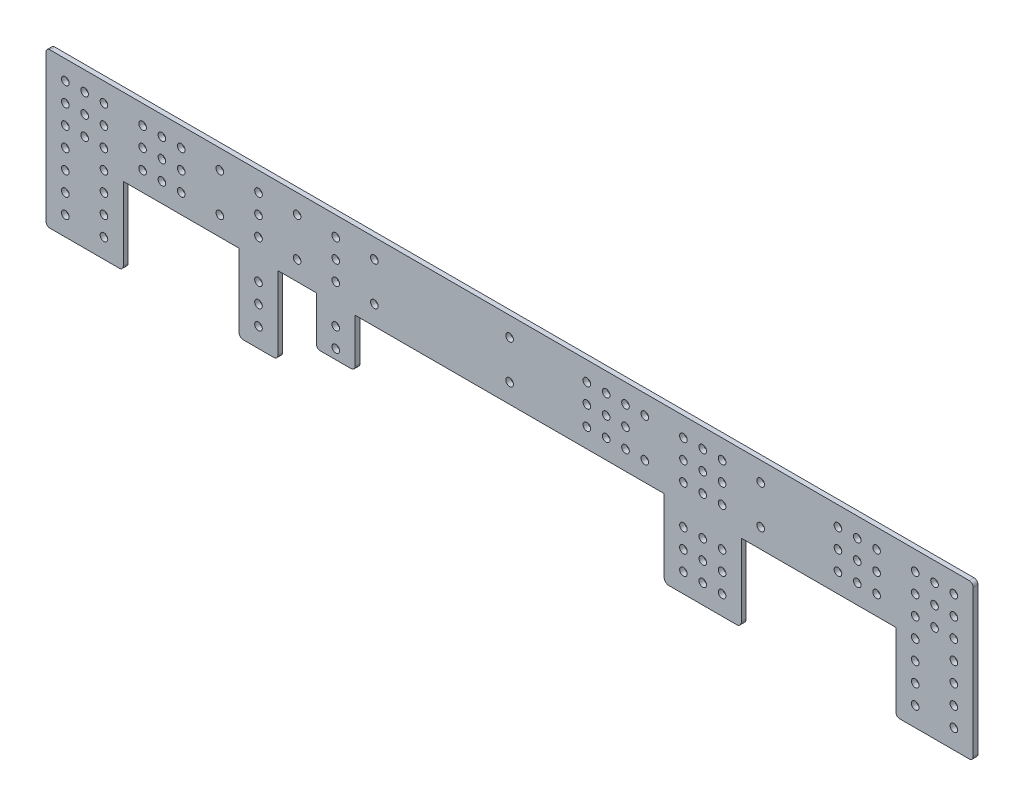
from build123d import *

# Parameters (mm, degrees)
BOSS_EXTRUDE1_DEPTH = 3.175
BOSS_EXTRUDE2_DEPTH = 3.175
BOSS_EXTRUDE3_DEPTH = 3.175
SKETCH7_R           = 2.505
SKETCH7_R_2         = 2.5
CUT_EXTRUDE3_DEPTH  = 4.175
SKETCH3_R           = 2.505
SKETCH3_R_2         = 2.5
CUT_EXTRUDE4_DEPTH  = 4.175
SKETCH8_R           = 2.5
CUT_EXTRUDE5_DEPTH  = 4.175
SKETCH9_R           = 2.5
CUT_EXTRUDE6_DEPTH  = 4.175


with BuildPart() as part:
    # Sketch2 → Boss-Extrude1 (new body)
    with BuildSketch(Plane.XY):
        with BuildLine():
            Line((126.386816889, -46.477764478), (-478.133183111, -46.477764478))
            ThreePointArc((-478.133183111, -46.477764478), (-479.929234335, -47.221713254), (-480.673183111, -49.017764478))
            Line((-480.673183111, -49.017764478), (-480.673183111, -97.277764478))
            Line((-480.673183111, -97.277764478), (-429.873183111, -97.277764478))
            Line((-429.873183111, -97.277764478), (78.126816889, -97.277764478))
            Line((78.126816889, -97.277764478), (128.926816889, -97.277764478))
            Line((128.926816889, -97.277764478), (128.926816889, -49.017764478))
            ThreePointArc((128.926816889, -49.017764478), (128.182868113, -47.221713254), (126.386816889, -46.477764478))
        make_face()
        with BuildLine():
            Line((-429.873183111, -97.277764478), (-480.673183111, -97.277764478))
            Line((-480.673183111, -97.277764478), (-480.673183111, -145.537764478))
            ThreePointArc((-480.673183111, -145.537764478), (-479.929234335, -147.333815702), (-478.133183111, -148.077764478))
            Line((-478.133183111, -148.077764478), (-432.413183111, -148.077764478))
            ThreePointArc((-432.413183111, -148.077764478), (-430.617131887, -147.333815702), (-429.873183111, -145.537764478))
            Line((-429.873183111, -145.537764478), (-429.873183111, -97.277764478))
        make_face()
        with BuildLine():
            Line((128.926816889, -145.537764478), (128.926816889, -97.277764478))
            Line((128.926816889, -97.277764478), (78.126816889, -97.277764478))
            Line((78.126816889, -97.277764478), (78.126816889, -145.537764478))
            ThreePointArc((78.126816889, -145.537764478), (78.870765665, -147.333815702), (80.666816889, -148.077764478))
            Line((80.666816889, -148.077764478), (126.386816889, -148.077764478))
            ThreePointArc((126.386816889, -148.077764478), (128.182868113, -147.333815702), (128.926816889, -145.537764478))
        make_face()
    extrude(amount=BOSS_EXTRUDE1_DEPTH)

    # Sketch4 → Boss-Extrude2 (add)
    with BuildSketch(Plane.XY.offset(3.175)):
        with BuildLine():
            Line((-353.673183111, -97.277764478), (-328.273183111, -97.277764478))
            Line((-328.273183111, -97.277764478), (-328.273183111, -145.537764478))
            ThreePointArc((-328.273183111, -145.537764478), (-329.017131887, -147.333815702), (-330.813183111, -148.077764478))
            Line((-330.813183111, -148.077764478), (-351.133183111, -148.077764478))
            ThreePointArc((-351.133183111, -148.077764478), (-352.929234335, -147.333815702), (-353.673183111, -145.537764478))
            Line((-353.673183111, -145.537764478), (-353.673183111, -97.277764478))
        make_face()
        with BuildLine():
            Line((-302.873183111, -97.277764478), (-277.473183111, -97.277764478))
            Line((-277.473183111, -97.277764478), (-277.473183111, -126.487764478))
            ThreePointArc((-277.473183111, -126.487764478), (-278.217131887, -128.283815702), (-280.013183111, -129.027764478))
            Line((-280.013183111, -129.027764478), (-300.333183111, -129.027764478))
            ThreePointArc((-300.333183111, -129.027764478), (-302.129234335, -128.283815702), (-302.873183111, -126.487764478))
            Line((-302.873183111, -126.487764478), (-302.873183111, -97.277764478))
        make_face()
    extrude(amount=-BOSS_EXTRUDE2_DEPTH)

    # Sketch6 → Boss-Extrude3 (add)
    with BuildSketch(Plane.XY.offset(3.175)):
        with BuildLine():
            Line((-23.473183111, -97.277764478), (-74.273183111, -97.277764478))
            Line((-74.273183111, -97.277764478), (-74.273183111, -144.902764478))
            ThreePointArc((-74.273183111, -144.902764478), (-73.343247141, -147.147828508), (-71.098183111, -148.077764478))
            Line((-71.098183111, -148.077764478), (-26.648183111, -148.077764478))
            ThreePointArc((-26.648183111, -148.077764478), (-24.403119081, -147.147828508), (-23.473183111, -144.902764478))
            Line((-23.473183111, -144.902764478), (-23.473183111, -97.277764478))
        make_face()
    extrude(amount=-BOSS_EXTRUDE3_DEPTH)

    # Sketch7 → Cut-Extrude3 (cut, through all)
    with BuildSketch(Plane.XY.offset(3.175)):
        with Locations((-61.573183111, -135.377764478)):
            Circle(SKETCH7_R)
        with Locations((-48.873183111, -135.377764478)):
            Circle(SKETCH7_R)
        with Locations((-36.173183111, -135.377764478)):
            Circle(SKETCH7_R)
        with Locations((-48.873183111, -122.677764478)):
            Circle(SKETCH7_R)
        with Locations((-36.173183111, -122.677764478)):
            Circle(SKETCH7_R)
        with Locations((-48.873183111, -109.977764478)):
            Circle(SKETCH7_R)
        with Locations((-36.173183111, -109.977764478)):
            Circle(SKETCH7_R)
        with Locations((-61.573183111, -122.677764478)):
            Circle(SKETCH7_R)
        with Locations((-61.573183111, -109.977764478)):
            Circle(SKETCH7_R)
        with Locations((-340.973183111, -109.977764478)):
            Circle(SKETCH7_R_2)
        with Locations((-290.173183111, -109.977764478)):
            Circle(SKETCH7_R_2)
        with Locations((-340.973183111, -122.677764478)):
            Circle(SKETCH7_R_2)
        with Locations((-340.973183111, -135.377764478)):
            Circle(SKETCH7_R_2)
        with Locations((-290.173183111, -122.677764478)):
            Circle(SKETCH7_R_2)
    extrude(amount=-CUT_EXTRUDE3_DEPTH, mode=Mode.SUBTRACT)

    # Sketch3 → Cut-Extrude4 (cut, through all)
    with BuildSketch(Plane.XY.offset(3.175)):
        with Locations((-467.973183111, -59.177764478)):
            Circle(SKETCH3_R)
        with Locations((-455.273183111, -59.177764478)):
            Circle(SKETCH3_R)
        with Locations((-442.573183111, -59.177764478)):
            Circle(SKETCH3_R)
        with Locations((-417.173183111, -59.177764478)):
            Circle(SKETCH3_R)
        with Locations((-404.473183111, -59.177764478)):
            Circle(SKETCH3_R)
        with Locations((-391.773183111, -59.177764478)):
            Circle(SKETCH3_R)
        with Locations((-366.373183111, -59.177764478)):
            Circle(SKETCH3_R)
        with Locations((-340.973183111, -59.177764478)):
            Circle(SKETCH3_R)
        with Locations((-315.573183111, -59.177764478)):
            Circle(SKETCH3_R)
        with Locations((-290.173183111, -59.177764478)):
            Circle(SKETCH3_R)
        with Locations((-264.773183111, -59.177764478)):
            Circle(SKETCH3_R)
        with Locations((-175.873183111, -59.177764478)):
            Circle(SKETCH3_R)
        with Locations((-86.973183111, -59.177764478)):
            Circle(SKETCH3_R)
        with Locations((-61.573183111, -59.177764478)):
            Circle(SKETCH3_R)
        with Locations((-48.873183111, -59.177764478)):
            Circle(SKETCH3_R)
        with Locations((-36.173183111, -59.177764478)):
            Circle(SKETCH3_R)
        with Locations((-10.773183111, -59.177764478)):
            Circle(SKETCH3_R)
        with Locations((40.026816889, -59.177764478)):
            Circle(SKETCH3_R)
        with Locations((52.726816889, -59.177764478)):
            Circle(SKETCH3_R)
        with Locations((65.426816889, -59.177764478)):
            Circle(SKETCH3_R)
        with Locations((90.826816889, -59.177764478)):
            Circle(SKETCH3_R)
        with Locations((103.526816889, -59.177764478)):
            Circle(SKETCH3_R)
        with Locations((116.226816889, -59.177764478)):
            Circle(SKETCH3_R)
        with Locations((-455.273183111, -71.877764478)):
            Circle(SKETCH3_R)
        with Locations((-442.573183111, -71.877764478)):
            Circle(SKETCH3_R)
        with Locations((-340.973183111, -71.877764478)):
            Circle(SKETCH3_R)
        with Locations((-290.173183111, -71.877764478)):
            Circle(SKETCH3_R)
        with Locations((-61.573183111, -71.877764478)):
            Circle(SKETCH3_R)
        with Locations((-48.873183111, -71.877764478)):
            Circle(SKETCH3_R)
        with Locations((-36.173183111, -71.877764478)):
            Circle(SKETCH3_R)
        with Locations((90.826816889, -71.877764478)):
            Circle(SKETCH3_R)
        with Locations((103.526816889, -71.877764478)):
            Circle(SKETCH3_R)
        with Locations((116.226816889, -71.877764478)):
            Circle(SKETCH3_R)
        with Locations((-455.273183111, -84.577764478)):
            Circle(SKETCH3_R)
        with Locations((-442.573183111, -84.577764478)):
            Circle(SKETCH3_R)
        with Locations((-417.173183111, -84.577764478)):
            Circle(SKETCH3_R)
        with Locations((-404.473183111, -84.577764478)):
            Circle(SKETCH3_R)
        with Locations((-391.773183111, -84.577764478)):
            Circle(SKETCH3_R)
        with Locations((-366.373183111, -84.577764478)):
            Circle(SKETCH3_R)
        with Locations((-340.973183111, -84.577764478)):
            Circle(SKETCH3_R)
        with Locations((-315.573183111, -84.577764478)):
            Circle(SKETCH3_R)
        with Locations((-290.173183111, -84.577764478)):
            Circle(SKETCH3_R)
        with Locations((-264.773183111, -84.577764478)):
            Circle(SKETCH3_R)
        with Locations((-175.873183111, -84.577764478)):
            Circle(SKETCH3_R)
        with Locations((-86.973183111, -84.577764478)):
            Circle(SKETCH3_R)
        with Locations((-61.573183111, -84.577764478)):
            Circle(SKETCH3_R)
        with Locations((-48.873183111, -84.577764478)):
            Circle(SKETCH3_R)
        with Locations((-36.173183111, -84.577764478)):
            Circle(SKETCH3_R)
        with Locations((-10.773183111, -84.577764478)):
            Circle(SKETCH3_R)
        with Locations((40.026816889, -84.577764478)):
            Circle(SKETCH3_R)
        with Locations((52.726816889, -84.577764478)):
            Circle(SKETCH3_R)
        with Locations((65.426816889, -84.577764478)):
            Circle(SKETCH3_R)
        with Locations((90.826816889, -84.577764478)):
            Circle(SKETCH3_R)
        with Locations((103.526816889, -84.577764478)):
            Circle(SKETCH3_R)
        with Locations((116.226816889, -84.577764478)):
            Circle(SKETCH3_R)
        with Locations((-467.973183111, -71.877764478)):
            Circle(SKETCH3_R)
        with Locations((-467.973183111, -84.577764478)):
            Circle(SKETCH3_R)
        with Locations((-467.973183111, -135.377764478)):
            Circle(SKETCH3_R)
        with Locations((-442.573183111, -135.377764478)):
            Circle(SKETCH3_R)
        with Locations((-442.573183111, -122.677764478)):
            Circle(SKETCH3_R)
        with Locations((-442.573183111, -109.977764478)):
            Circle(SKETCH3_R)
        with Locations((-442.573183111, -97.277764478)):
            Circle(SKETCH3_R)
        with Locations((-467.973183111, -122.677764478)):
            Circle(SKETCH3_R)
        with Locations((-467.973183111, -109.977764478)):
            Circle(SKETCH3_R)
        with Locations((-467.973183111, -97.277764478)):
            Circle(SKETCH3_R)
        with Locations((90.826816889, -135.377764478)):
            Circle(SKETCH3_R)
        with Locations((116.226816889, -135.377764478)):
            Circle(SKETCH3_R)
        with Locations((116.226816889, -122.677764478)):
            Circle(SKETCH3_R)
        with Locations((116.226816889, -109.977764478)):
            Circle(SKETCH3_R)
        with Locations((116.226816889, -97.277764478)):
            Circle(SKETCH3_R)
        with Locations((90.826816889, -122.677764478)):
            Circle(SKETCH3_R)
        with Locations((90.826816889, -109.977764478)):
            Circle(SKETCH3_R)
        with Locations((90.826816889, -97.277764478)):
            Circle(SKETCH3_R)
        with Locations((-417.173183111, -71.877764478)):
            Circle(SKETCH3_R_2)
        with Locations((-404.473183111, -71.877764478)):
            Circle(SKETCH3_R_2)
        with Locations((-391.773183111, -71.877764478)):
            Circle(SKETCH3_R_2)
        with Locations((65.426816889, -71.877764478)):
            Circle(SKETCH3_R_2)
        with Locations((52.726816889, -71.877764478)):
            Circle(SKETCH3_R_2)
        with Locations((40.026816889, -71.877764478)):
            Circle(SKETCH3_R_2)
    extrude(amount=-CUT_EXTRUDE4_DEPTH, mode=Mode.SUBTRACT)

    # Sketch8 → Cut-Extrude5 (cut, through all)
    with BuildSketch(Plane.XY.offset(3.175)):
        with Locations((-112.373183111, -71.877764478)):
            Circle(SKETCH8_R)
    extrude(amount=-CUT_EXTRUDE5_DEPTH, mode=Mode.SUBTRACT)

    # Sketch9 → Cut-Extrude6 (cut, through all)
    with BuildSketch(Plane.XY.offset(3.175)):
        with Locations((-125.073183111, -59.177764478)):
            Circle(SKETCH9_R)
        with Locations((-112.373183111, -59.177764478)):
            Circle(SKETCH9_R)
        with Locations((-99.673183111, -59.177764478)):
            Circle(SKETCH9_R)
        with Locations((-99.673183111, -71.877764478)):
            Circle(SKETCH9_R)
        with Locations((-112.373183111, -84.577764478)):
            Circle(SKETCH9_R)
        with Locations((-99.673183111, -84.577764478)):
            Circle(SKETCH9_R)
        with Locations((-125.073183111, -71.877764478)):
            Circle(SKETCH9_R)
        with Locations((-125.073183111, -84.577764478)):
            Circle(SKETCH9_R)
    extrude(amount=-CUT_EXTRUDE6_DEPTH, mode=Mode.SUBTRACT)


solid = part.part
